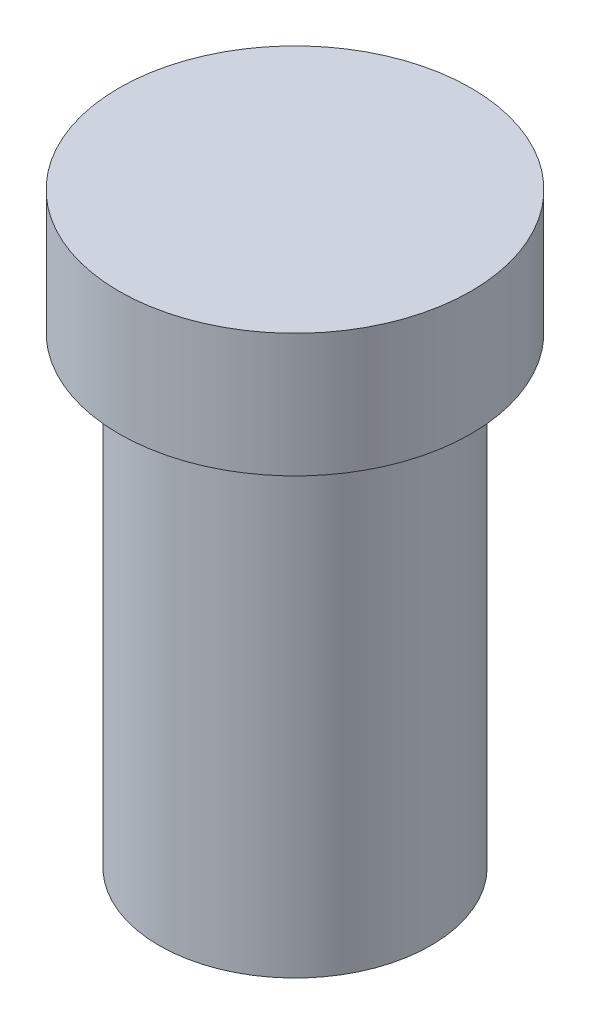
from build123d import *

# Parameters (mm, degrees)
SKETCH1_R           = 22
BOSS_EXTRUDE1_DEPTH = 75
SKETCH2_R           = 28.5
BOSS_EXTRUDE2_DEPTH = 20


with BuildPart() as part:
    # Sketch1 → Boss-Extrude1 (new body)
    with BuildSketch(Plane(origin=(0, 0, 0), x_dir=(1, 0, 0), z_dir=(0, 1, 0))):
        with Locations(Location((0, 0, 0), (0, 0, 270))):  # turned: the seam where the file's is
            Circle(SKETCH1_R)
    extrude(amount=BOSS_EXTRUDE1_DEPTH)

    # Sketch2 → Boss-Extrude2 (add)
    with BuildSketch(Plane(origin=(0, 75, 0), x_dir=(1, 0, 0), z_dir=(0, 1, 0))):
        with Locations(Location((0, 0, 0), (0, 0, 270))):  # turned: the seam where the file's is
            Circle(SKETCH2_R)
    extrude(amount=BOSS_EXTRUDE2_DEPTH)


solid = part.part
